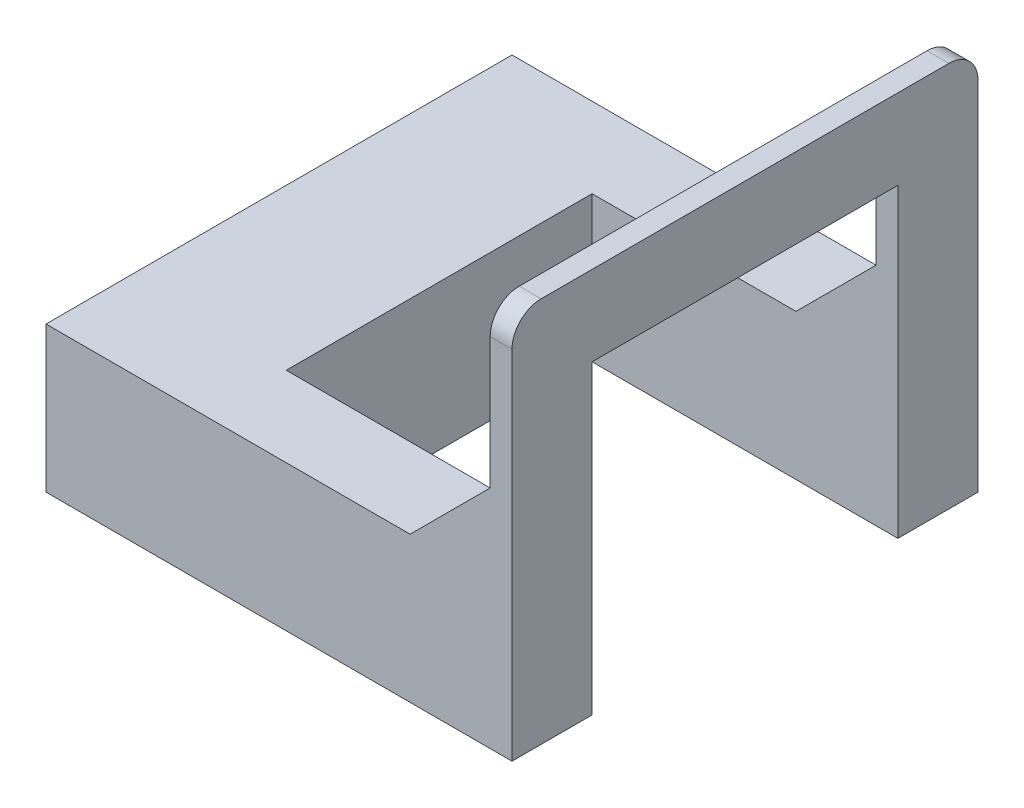
from build123d import *

# Parameters (mm, degrees)
EXTRUDE_1_DEPTH = 100
EXTRUDE_2_DEPTH = 15
EXTRUDE_3_DEPTH = 55
EXTRUDE_4_DEPTH = 55
FILLET_1_R      = 20


with BuildPart() as part:
    # 草图1 → 凸台-拉伸1 (new body)
    with BuildSketch(Plane(origin=(0, 0, 0), x_dir=(1, 0, 0), z_dir=(0, 1, 0))):
        Polygon((0, 0), (320, 0), (320, 55), (110, 55), (110, 265), (320, 265), (320, 320), (0, 320), align=None)
    extrude(amount=EXTRUDE_1_DEPTH)

    # 草图2 → 凸台-拉伸2 (add)
    with BuildSketch(Plane(origin=(320, 0, 0), x_dir=(0, 0, -1), z_dir=(1, 0, 0))):
        Polygon((0, 0), (0, 265), (320, 265), (320, 0), (265, 0), (265, 210), (55, 210), (55, 0), align=None)
    extrude(amount=-EXTRUDE_2_DEPTH)

    # 草图3 → 凸台-拉伸3 (add)
    with BuildSketch(Plane.XY):
        Polygon((250, 100), (305, 100), (305, 155), align=None)
    extrude(amount=-EXTRUDE_3_DEPTH)

    # 草图4 → 凸台-拉伸4 (add)
    with BuildSketch(Plane(origin=(0, 0, -320), x_dir=(-1, 0, 0), z_dir=(0, 0, -1))):
        Polygon((-305, 155), (-305, 100), (-250, 100), align=None)
    extrude(amount=-EXTRUDE_4_DEPTH)

    # 圆角1
    fillet_1_edges = [part.edges().sort_by_distance(p)[0] for p in [
        (312.5, 265, -320),
        (312.5, 265, 0),
    ]]
    fillet(fillet_1_edges, radius=FILLET_1_R)


solid = part.part
